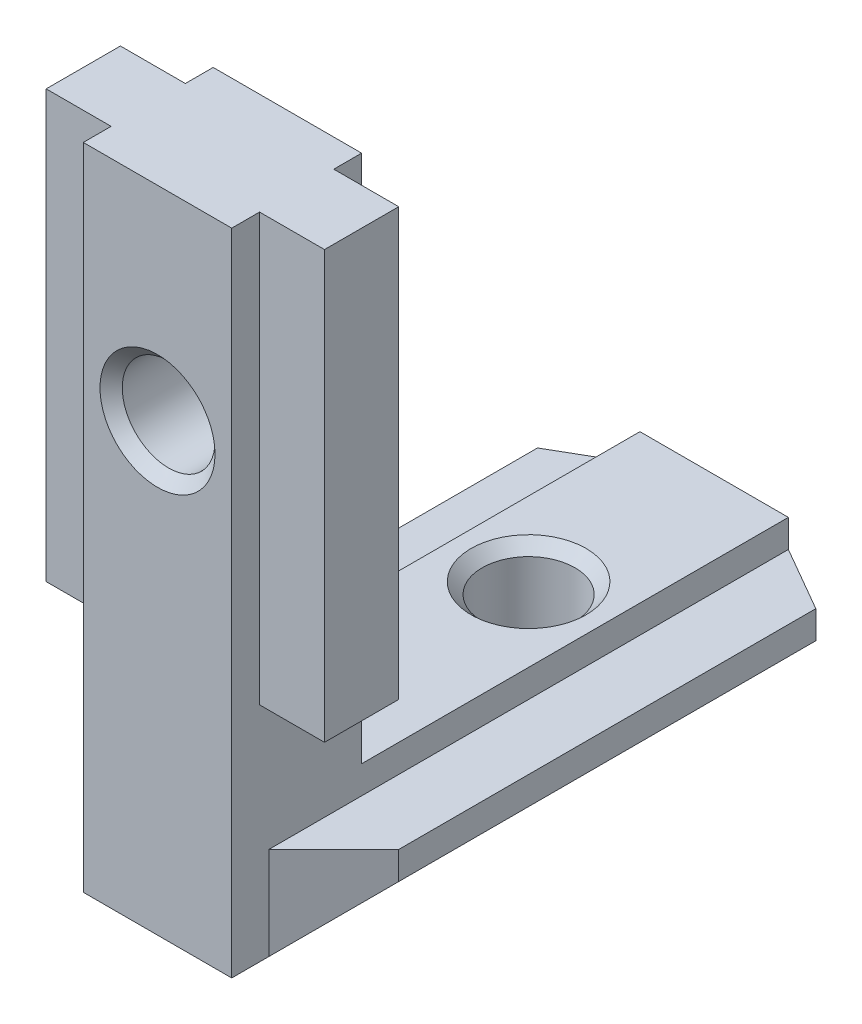
from build123d import *

# Parameters (mm, degrees)
EXTRUDE_1_DEPTH     = 30
SKETCH_2_W          = 7
SKETCH_2_H          = 35
EXTRUDE_2_DEPTH     = 4
CUT_EXTRUDE_1_DEPTH = 6
SKETCH_4_W          = 15
SKETCH_4_H          = 4
EXTRUDE_3_DEPTH     = 23


with BuildPart() as part:
    # Эскиз1 → Бобышка-Вытянуть1 (new body)
    with BuildSketch(Plane.XY):
        Polygon((4, 0), (-4, 0), (-4, -1.5), (-7.5, -1.5), (-7.5, -3), (-4, -6.5), (4, -6.5), (7.5, -3), (7.5, -1.5), (4, -1.5), align=None)
    extrude(amount=EXTRUDE_1_DEPTH)

    # Эскиз2 → Бобышка-Вытянуть2 (add, symmetric)
    with BuildSketch(Plane(origin=(0, 0, 0), x_dir=(0, 0, -1), z_dir=(1, 0, 0))):
        with Locations((-26.5, 11)):
            Rectangle(SKETCH_2_W, SKETCH_2_H)
    extrude(amount=EXTRUDE_2_DEPTH, both=True)

    # Эскиз3 → Вырез-Вытянуть1 (cut, through all)
    with BuildSketch(Plane(origin=(0, -1.5, 0), x_dir=(1, 0, 0), z_dir=(0, 1, 0))):
        Polygon((-4, 0), (-7.5, -2.020725942), (-7.5, 0), align=None)
        Polygon((-4, -28), (-7.5, -24.5), (-7.5, -30), (-4, -30), align=None)
        Polygon((4, -30), (4, -28), (7.5, -24.5), (7.5, -30), align=None)
        Polygon((7.5, 0), (4, 0), (7.5, -2.020725942), align=None)
    extrude(amount=-CUT_EXTRUDE_1_DEPTH, mode=Mode.SUBTRACT)

    # Эскиз4 → Бобышка-Вытянуть3 (add)
    with BuildSketch(Plane(origin=(0, 28.5, 0), x_dir=(1, 0, 0), z_dir=(0, 1, 0))):
        with Locations((0, -26.5)):
            Rectangle(SKETCH_4_W, SKETCH_4_H)
    extrude(amount=-EXTRUDE_3_DEPTH)

    # Эскиз6 → Отверстие обработанное метчиком M61 (revolve, cut)
    with BuildSketch(Plane(origin=(0, -6.5, 10), x_dir=(0, 0, -1), z_dir=(1, 0, 0))):
        Polygon((0, 0), (0, 6.5), (3.1, 6.5), (2.5, 5.9), (2.5, 0.6), (3.1, 0), align=None)
    revolve(axis=Axis((0, -12.85, 10), (0, 1, 0)), mode=Mode.SUBTRACT)

    # Эскиз8 → Отверстие обработанное метчиком M62 (revolve, cut)
    with BuildSketch(Plane(origin=(0, 17.5, 30), x_dir=(0, -1, 0), z_dir=(1, 0, 0))):
        Polygon((0, 0), (0, 7), (3.1, 7), (2.5, 6.4), (2.5, 0.6), (3.1, 0), align=None)
    revolve(axis=Axis((0, 17.5, 36.35), (0, 0, -1)), mode=Mode.SUBTRACT)


solid = part.part
